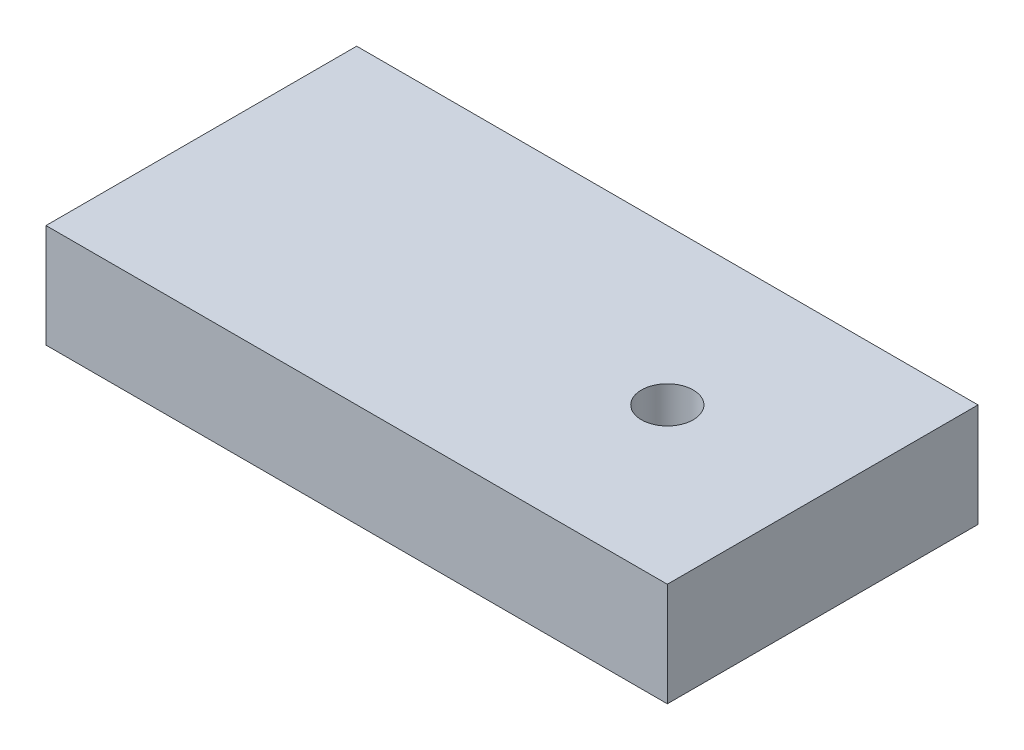
from build123d import *

# Parameters (mm, degrees)
SKETCH1_W           = 76.2
SKETCH1_H           = 38.1
BOSS_EXTRUDE1_DEPTH = 12.7
SKETCH2_R           = 3.175
CUT_EXTRUDE1_DEPTH  = 13.7
SKETCH3_R           = 6.35
CUT_EXTRUDE2_DEPTH  = 3


with BuildPart() as part:
    # Sketch1 → Boss-Extrude1 (new body)
    with BuildSketch(Plane(origin=(0, 0, 0), x_dir=(1, 0, 0), z_dir=(0, 1, 0))):
        with Locations((38.1, 19.05)):
            Rectangle(SKETCH1_W, SKETCH1_H)
    extrude(amount=BOSS_EXTRUDE1_DEPTH)

    # Sketch2 → Cut-Extrude1 (cut, through all)
    with BuildSketch(Plane.XZ):
        with Locations((57.15, -19.05)):
            Circle(SKETCH2_R)
    extrude(amount=-CUT_EXTRUDE1_DEPTH, mode=Mode.SUBTRACT)

    # Sketch3 → Cut-Extrude2 (cut)
    with BuildSketch(Plane.XZ):
        with Locations((57.15, -19.05)):
            Circle(SKETCH3_R)
    extrude(amount=-CUT_EXTRUDE2_DEPTH, mode=Mode.SUBTRACT)


solid = part.part
